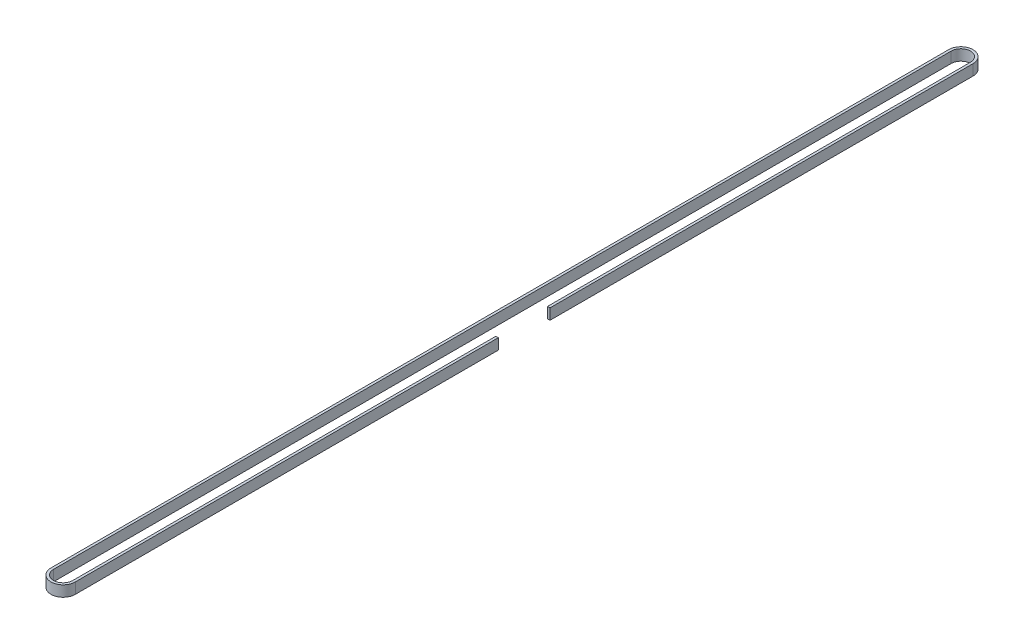
from build123d import *

# Parameters (mm, degrees)
EXTRUDE_THIN1_DEPTH = 6


with BuildPart() as part:
    # Sketch1 → Extrude-Thin1 (new body)
    with BuildSketch(Plane(origin=(0, 0, 0), x_dir=(1, 0, 0), z_dir=(0, 1, 0))):
        with BuildLine():
            Line((355.746, -59.767481844), (355.746, -294.767481844))
            ThreePointArc((355.746, -294.767481844), (350.38, -300.133481844), (345.014, -294.767481844))
            Line((345.014, -294.767481844), (345.014, 203.982518156))
            ThreePointArc((345.014, 203.982518156), (350.38, 209.348518156), (355.746, 203.982518156))
            Line((355.746, 203.982518156), (355.746, -31.017481844))
            Line((355.746, -31.017481844), (357.126, -31.017481844))
            Line((357.126, -31.017481844), (357.126, 203.982518156))
            ThreePointArc((357.126, 203.982518156), (350.38, 210.728518156), (343.634, 203.982518156))
            Line((343.634, 203.982518156), (343.634, -294.767481844))
            ThreePointArc((343.634, -294.767481844), (350.38, -301.513481844), (357.126, -294.767481844))
            Line((357.126, -294.767481844), (357.126, -59.767481844))
            Line((357.126, -59.767481844), (355.746, -59.767481844))
        make_face()
    extrude(amount=EXTRUDE_THIN1_DEPTH)


solid = part.part
